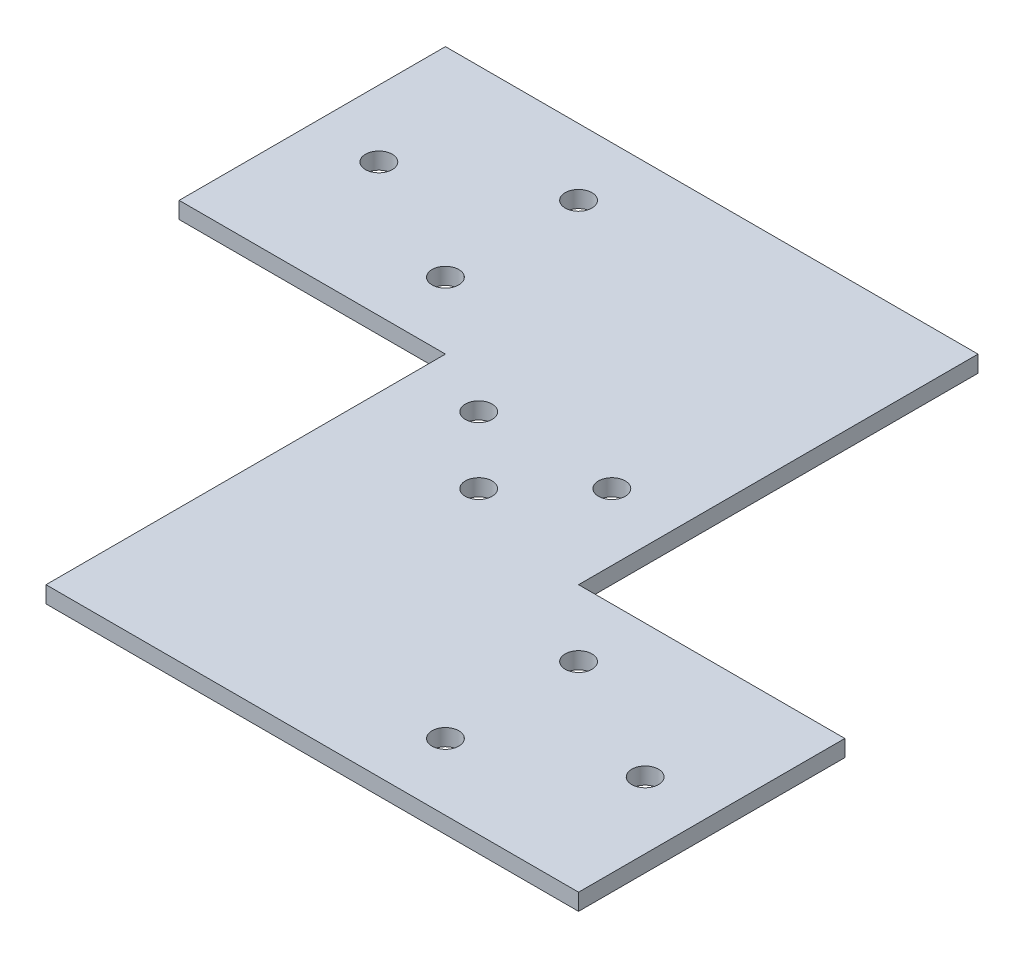
from build123d import *

# Parameters (mm, degrees)
SKETCH1_R           = 2.5527
BOSS_EXTRUDE1_DEPTH = 3.175


with BuildPart() as part:
    # Sketch1 → Boss-Extrude1 (new body)
    with BuildSketch(Plane(origin=(0, 0, 0), x_dir=(1, 0, 0), z_dir=(0, 1, 0))):
        Polygon((0, 0), (50.8, 0), (50.8, -76.2), (101.6, -76.2), (152.4, -76.2), (152.4, -25.4), (101.6, -25.4), (101.6, 50.8), (0, 50.8), align=None)
        with Locations((12.7, 25.4)):
            Circle(SKETCH1_R, mode=Mode.SUBTRACT)
        with Locations((38.1, 12.7)):
            Circle(SKETCH1_R, mode=Mode.SUBTRACT)
        with Locations((38.1, 38.1)):
            Circle(SKETCH1_R, mode=Mode.SUBTRACT)
        with Locations((139.7, -50.8)):
            Circle(SKETCH1_R, mode=Mode.SUBTRACT)
        with Locations((114.3, -38.1)):
            Circle(SKETCH1_R, mode=Mode.SUBTRACT)
        with Locations((114.3, -63.5)):
            Circle(SKETCH1_R, mode=Mode.SUBTRACT)
        with Locations((63.5, -6.35)):
            Circle(SKETCH1_R, mode=Mode.SUBTRACT)
        with Locations((88.9, -6.35)):
            Circle(SKETCH1_R, mode=Mode.SUBTRACT)
        with Locations((76.2, -19.05)):
            Circle(SKETCH1_R, mode=Mode.SUBTRACT)
    extrude(amount=BOSS_EXTRUDE1_DEPTH)


solid = part.part
